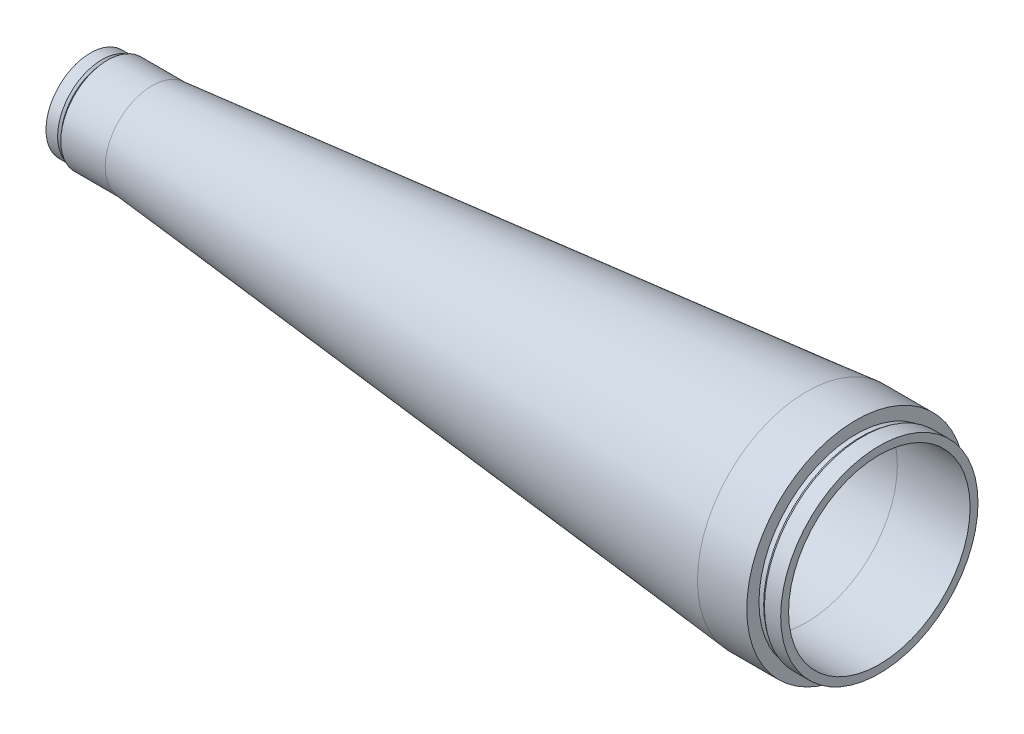
from build123d import *


with BuildPart() as part:
    # Skica1 → Rotovat1 (revolve)
    with BuildSketch(Plane.XY):
        Polygon((-36.713340937, -44.25), (-56.713340937, -44.25), (-322.05, -19), (-340.05, -19), (-340.05, -17.3), (-341.55, -17.3), (-342.35, -18), (-347.05, -18), (-347.05, -15.5), (-345.05, -15.5), (-325.964213562, -15.5), (-324.964213562, -16.5), (-323.75, -16.5), (-323.75, -15.4), (-322.05, -15.4), (-322.05, -12.9), (-217.05, -23.4), (-217.05, -25.4), (-215.55, -25.4), (-215.55, -26.9), (-213.932233047, -26.9), (-212.632233047, -25.6), (-117.05, -29.4), (-117.05, -33.4), (-115.55, -33.4), (-115.55, -34.5), (-113.1872583, -34.5), (-112.099684413, -33.412426112), (-56.713340937, -36.8), (-27.213340937, -36.8), (-27.213340937, -40), (-33.813340937, -40), (-34.813340937, -39.3), (-36.713340937, -39.3), align=None)
    revolve(axis=Axis((-172.442437001, 0, 0), (1, 0, 0)))


solid = part.part
